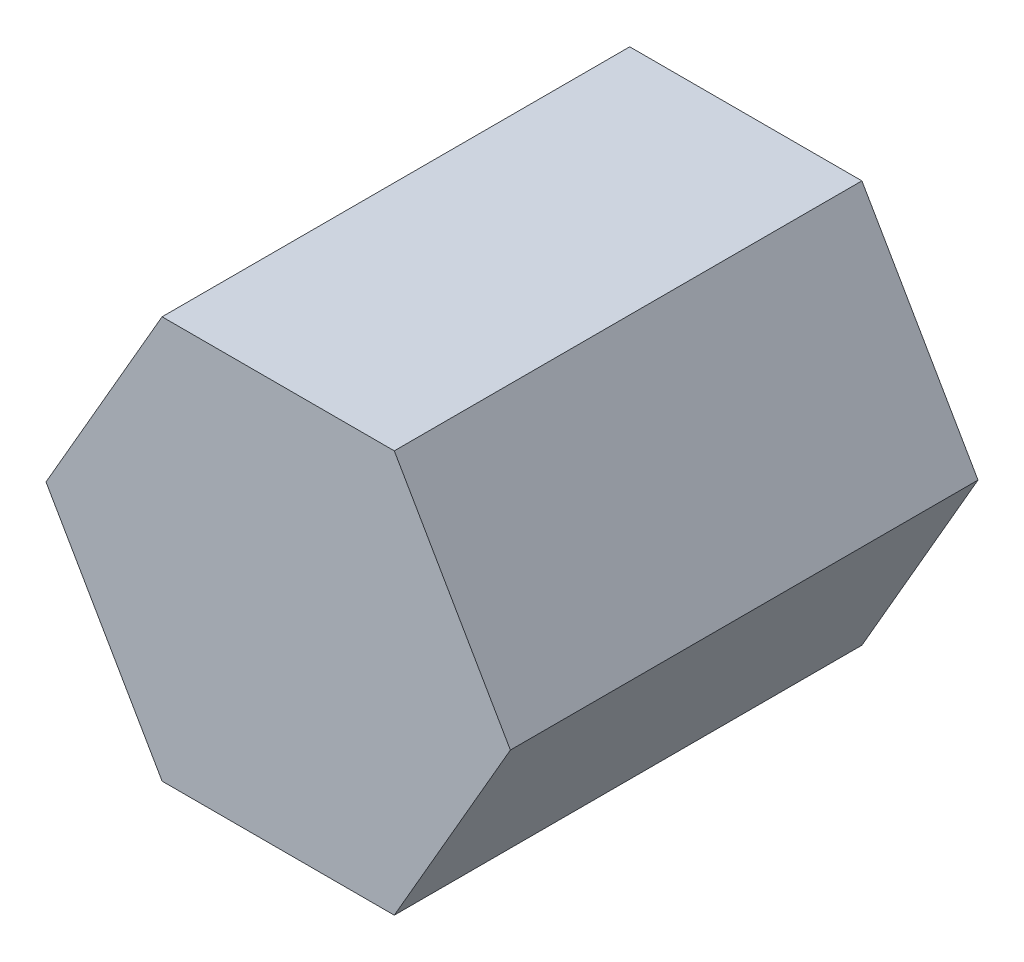
from build123d import *

# Parameters (mm, degrees)
BOSS_EXTRUDE1_DEPTH = 12.7


with BuildPart() as part:
    # Sketch1 → Boss-Extrude1 (new body)
    with BuildSketch(Plane.XY):
        Polygon((-0.443508154, -0.30895487), (5.862311486, -0.30895487), (9.015221306, -5.76995487), (5.862311486, -11.23095487), (-0.443508154, -11.23095487), (-3.596417974, -5.76995487), align=None)
    extrude(amount=BOSS_EXTRUDE1_DEPTH)


solid = part.part
